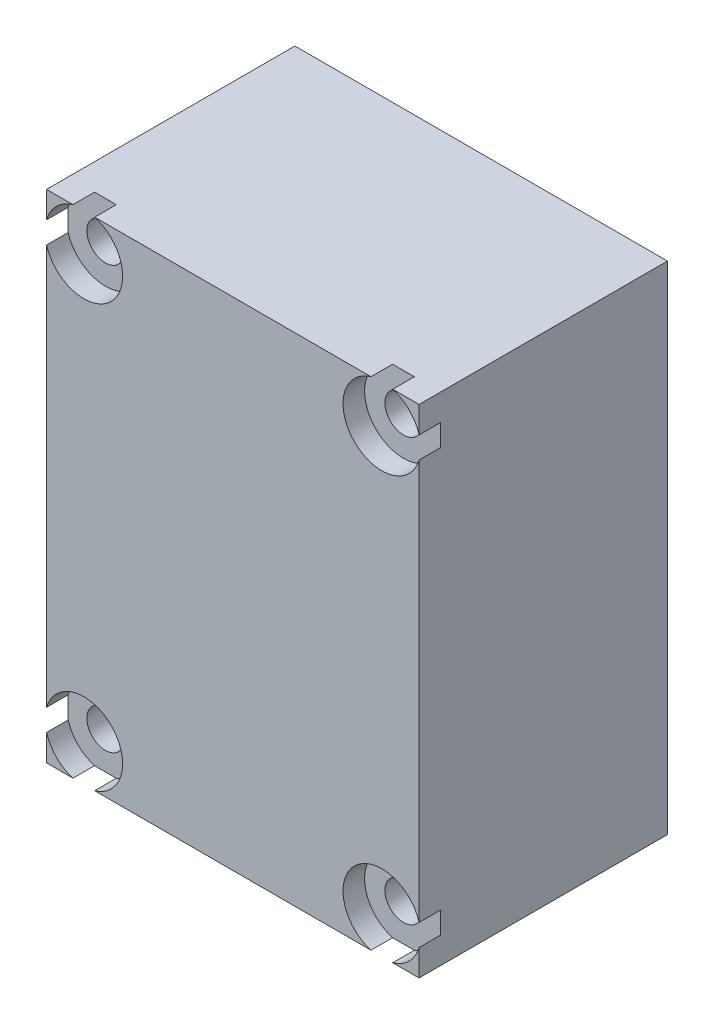
from build123d import *

# Parameters (mm, degrees)
SKETCH2_W                                           = 38.1
SKETCH2_H                                           = 50.8
BOSS_EXTRUDE1_DEPTH                                 = 25.4
CBORE_FOR_6_BINDING_HEAD_MACHINE_SCREW1_D           = 3.7973
CBORE_FOR_6_BINDING_HEAD_MACHINE_SCREW1_CBORE_D     = 7.9375
CBORE_FOR_6_BINDING_HEAD_MACHINE_SCREW1_CBORE_DEPTH = 2.2098


with BuildPart() as part:
    # Sketch2 → Boss-Extrude1 (new body)
    with BuildSketch(Plane.XY):
        with Locations((-32.515060241, 13.847590361)):
            Rectangle(SKETCH2_W, SKETCH2_H)
    extrude(amount=BOSS_EXTRUDE1_DEPTH)

    # CBORE for #6 Binding Head Machine Screw1 (through all)
    with Locations(Plane(origin=(-47.755060241, 35.437590361, 25.4), x_dir=(1, 0, 0), z_dir=(0, 0, 1))):
        with Locations((0, 0), (30.48, 0), (0, -43.18), (30.48, -43.18)):
            CounterBoreHole(CBORE_FOR_6_BINDING_HEAD_MACHINE_SCREW1_D / 2, CBORE_FOR_6_BINDING_HEAD_MACHINE_SCREW1_CBORE_D / 2, CBORE_FOR_6_BINDING_HEAD_MACHINE_SCREW1_CBORE_DEPTH)


solid = part.part
